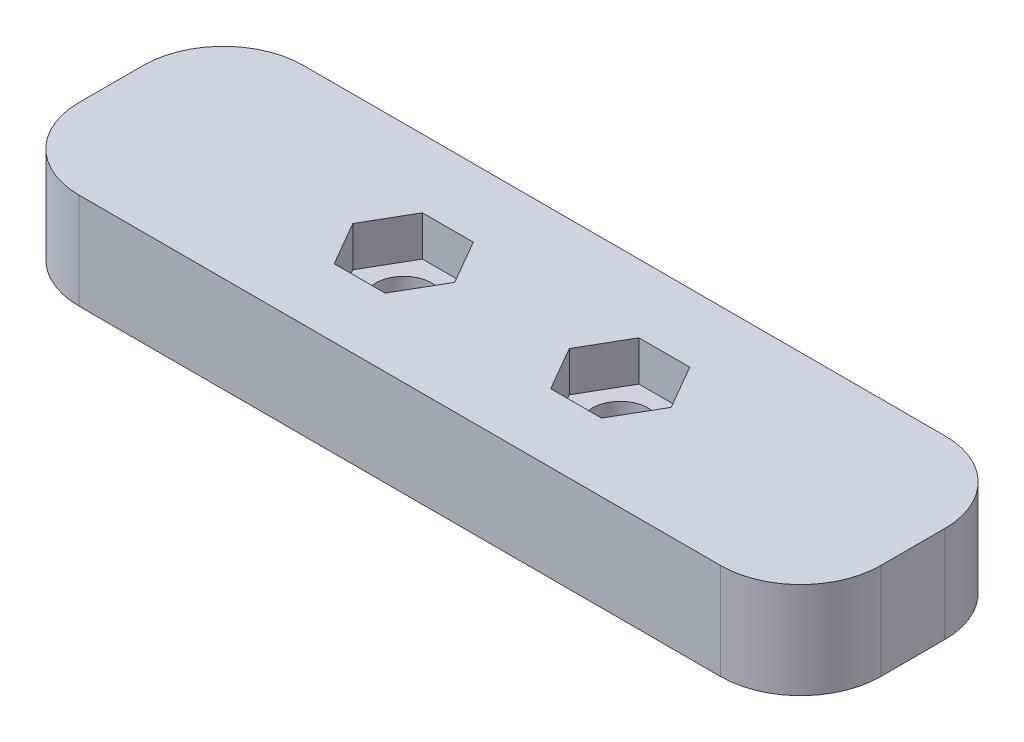
from build123d import *

# Parameters (mm, degrees)
SKETCH1_R           = 1.75
BOSS_EXTRUDE1_DEPTH = 6
CUT_EXTRUDE1_DEPTH  = 2.5


with BuildPart() as part:
    # Sketch1 → Boss-Extrude1 (new body)
    with BuildSketch(Plane(origin=(0, 0, 0), x_dir=(1, 0, 0), z_dir=(0, 1, 0))):
        with BuildLine():
            Line((5, 0), (45, 0))
            ThreePointArc((45, 0), (48.535533906, 1.464466094), (50, 5))
            Line((50, 5), (50, 9))
            ThreePointArc((50, 9), (48.535533906, 12.535533906), (45, 14))
            Line((45, 14), (5, 14))
            ThreePointArc((5, 14), (1.464466094, 12.535533906), (0, 9))
            Line((0, 9), (0, 5))
            ThreePointArc((0, 5), (1.464466094, 1.464466094), (5, 0))
        make_face()
        with Locations((18.25, 7)):
            Circle(SKETCH1_R, mode=Mode.SUBTRACT)
        with Locations((31.75, 7)):
            Circle(SKETCH1_R, mode=Mode.SUBTRACT)
    extrude(amount=BOSS_EXTRUDE1_DEPTH)

    # Sketch2 → Cut-Extrude1 (cut)
    with BuildSketch(Plane(origin=(0, 6, 0), x_dir=(1, 0, 0), z_dir=(0, 1, 0))):
        Polygon((19.83771324, 4.25), (21.425426481, 7), (19.83771324, 9.75), (16.66228676, 9.75), (15.074573519, 7), (16.66228676, 4.25), align=None)
        Polygon((33.33771324, 4.25), (34.925426481, 7), (33.33771324, 9.75), (30.16228676, 9.75), (28.574573519, 7), (30.16228676, 4.25), align=None)
    extrude(amount=-CUT_EXTRUDE1_DEPTH, mode=Mode.SUBTRACT)


solid = part.part
